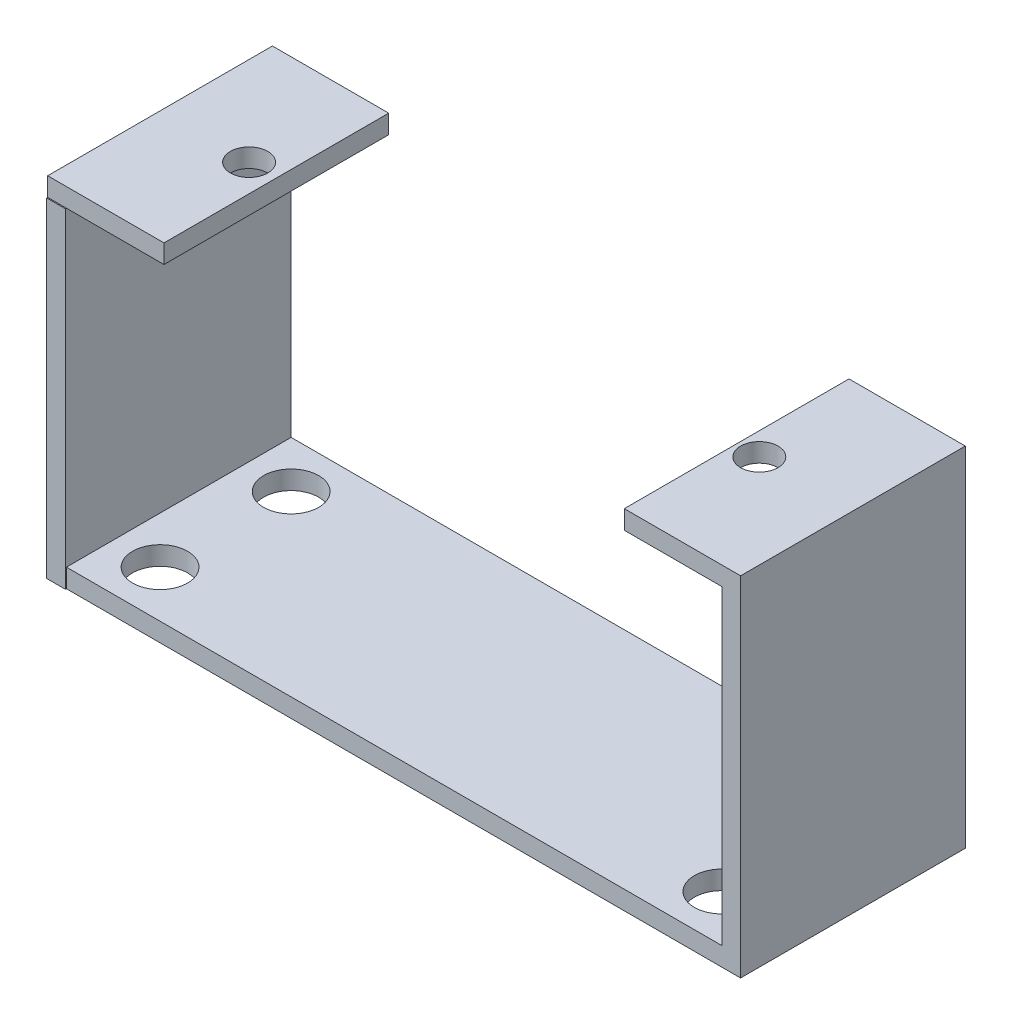
from build123d import *

# Parameters (mm, degrees)
SKETCH1_W           = 35
SKETCH1_H           = 12
BOSS_EXTRUDE1_DEPTH = 1
SKETCH2_W           = 12.053455819
SKETCH2_H           = 17.6
BOSS_EXTRUDE2_DEPTH = 1
SKETCH3_W           = 12
SKETCH3_H           = 17.6
BOSS_EXTRUDE3_DEPTH = 1
SKETCH5_W           = 37
SKETCH5_H           = 12
BOSS_EXTRUDE4_DEPTH = 1
SKETCH6_W           = 24.58
SKETCH6_H           = 12
CUT_EXTRUDE1_DEPTH  = 1
SKETCH7_R           = 1
CUT_EXTRUDE2_DEPTH  = 1
SKETCH8_R           = 1
CUT_EXTRUDE3_DEPTH  = 1
SKETCH9_R           = 1.47
CUT_EXTRUDE4_DEPTH  = 10


with BuildPart() as part:
    # Sketch1 → Boss-Extrude1 (new body)
    with BuildSketch(Plane(origin=(0, 0, 0), x_dir=(1, 0, 0), z_dir=(0, 1, 0))):
        with Locations((0.180945347, -2.562038405)):
            Rectangle(SKETCH1_W, SKETCH1_H)
    extrude(amount=BOSS_EXTRUDE1_DEPTH)

    # Sketch2 → Boss-Extrude2 (add)
    with BuildSketch(Plane.ZY.offset(17.319054653)):
        with Locations((2.588766314, 8.8)):
            Rectangle(SKETCH2_W, SKETCH2_H)
    extrude(amount=BOSS_EXTRUDE2_DEPTH)

    # Sketch3 → Boss-Extrude3 (add)
    with BuildSketch(Plane(origin=(17.680945347, 0, 0), x_dir=(0, 0, -1), z_dir=(1, 0, 0))):
        with Locations((-2.562038405, 8.8)):
            Rectangle(SKETCH3_W, SKETCH3_H)
    extrude(amount=BOSS_EXTRUDE3_DEPTH)

    # Sketch5 → Boss-Extrude4 (add)
    with BuildSketch(Plane(origin=(0, 17.6, 0), x_dir=(1, 0, 0), z_dir=(0, 1, 0))):
        with Locations((0.180945347, -2.562038405)):
            Rectangle(SKETCH5_W, SKETCH5_H)
    extrude(amount=BOSS_EXTRUDE4_DEPTH)

    # Sketch6 → Cut-Extrude1 (cut)
    with BuildSketch(Plane(origin=(0, 18.6, 0), x_dir=(1, 0, 0), z_dir=(0, 1, 0))):
        with Locations((0.180945347, -2.562038405)):
            Rectangle(SKETCH6_W, SKETCH6_H)
    extrude(amount=-CUT_EXTRUDE1_DEPTH, mode=Mode.SUBTRACT)

    # Sketch7 → Cut-Extrude2 (cut)
    with BuildSketch(Plane(origin=(0, 18.6, 0), x_dir=(1, 0, 0), z_dir=(0, 1, 0))):
        with Locations((13.680945347, -2.562038405)):
            Circle(SKETCH7_R)
    extrude(amount=-CUT_EXTRUDE2_DEPTH, mode=Mode.SUBTRACT)

    # Sketch8 → Cut-Extrude3 (cut)
    with BuildSketch(Plane(origin=(0, 18.6, 0), x_dir=(1, 0, 0), z_dir=(0, 1, 0))):
        with Locations((-13.569054453, -2.558738176)):
            Circle(SKETCH8_R)
    extrude(amount=-CUT_EXTRUDE3_DEPTH, mode=Mode.SUBTRACT)

    # Sketch9 → Cut-Extrude4 (cut)
    with BuildSketch(Plane(origin=(0, 1, 0), x_dir=(1, 0, 0), z_dir=(0, 1, 0))):
        with Locations((15.180945347, 0.937961595)):
            Circle(SKETCH9_R)
        with Locations((15.180945347, -6.062038405)):
            Circle(SKETCH9_R)
        with Locations((-14.819054653, 0.937961595)):
            Circle(SKETCH9_R)
        with Locations((-14.819054653, -6.062038405)):
            Circle(SKETCH9_R)
    extrude(amount=-CUT_EXTRUDE4_DEPTH, mode=Mode.SUBTRACT)


solid = part.part
